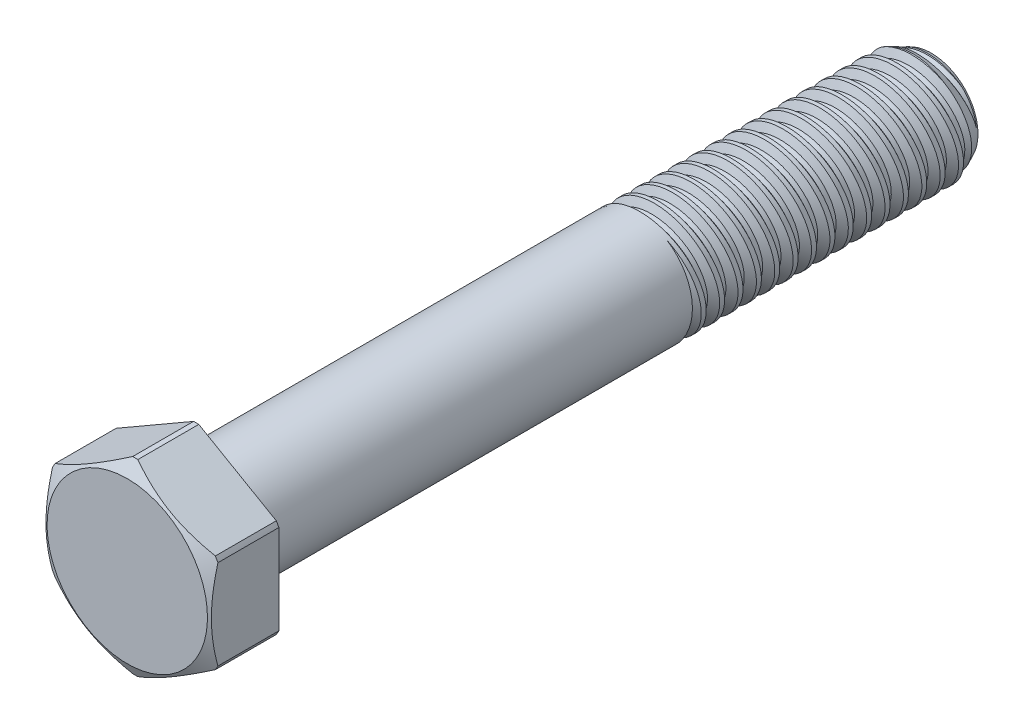
from build123d import *

# Parameters (mm, degrees)
SKETCH1_W            = 25.4
SKETCH1_H            = 4.7625
LPATTERN1_COUNT      = 2
LPATTERN1_PITCH      = 1.5875
LPATTERN1_COUNT_DIR2 = 16
LPATTERN1_PITCH_DIR2 = 1.5875
SKETCH4_W            = 38.1
SKETCH4_H            = 4.7625
EXTRUDE1_DEPTH       = 5.953125
FILLET1_R            = 0.9525


with BuildPart() as part:
    # Sketch1 → Revolve1 (revolve)
    with BuildSketch(Plane(origin=(0, 0, 0), x_dir=(0, 0, -1), z_dir=(1, 0, 0))):
        with Locations((12.7, 2.38125)):
            Rectangle(SKETCH1_W, SKETCH1_H)
    revolve(axis=Axis((0, 0, 0), (0, 0, 1)))

    # Sketch2 → Cut-Revolve1 (revolve, cut)
    with BuildSketch(Plane(origin=(0, 0, 0), x_dir=(0, 0, -1), z_dir=(1, 0, 0))):
        Polygon((1.565900354, 5.023483392), (0.195737544, 4.795122924), (0.82634281, 4.029111805), (1.217817898, 4.094357653), align=None)
    cut_revolve1 = revolve(axis=Axis((0, -0.28317269, 0), (0, 0.164398987, -0.986393924)), mode=Mode.SUBTRACT)

    # Sketch3 → Cut-Revolve2 (revolve, cut)
    with BuildSketch(Plane(origin=(0, 0, 0), x_dir=(0, 0, -1), z_dir=(1, 0, 0))):
        Polygon((23.827243941, 4.7625), (25.4, 4.029111805), (25.4, 4.7625), align=None)
    revolve(axis=Axis((0, 0, 0), (0, 0, -1)), mode=Mode.SUBTRACT)

    # LPattern1: Cut-Revolve1 2 × 16
    with Locations(*[Vector(0, 0, 1) * (i * LPATTERN1_PITCH) + Vector(0, 0, -1) * (j * LPATTERN1_PITCH_DIR2) for i in range(LPATTERN1_COUNT) for j in range(LPATTERN1_COUNT_DIR2) if (i, j) != (0, 0)]):
        add(cut_revolve1, mode=Mode.SUBTRACT)

    # Sketch4 → Revolve2 (revolve)
    with BuildSketch(Plane(origin=(0, 0, 0), x_dir=(0, 0, -1), z_dir=(1, 0, 0))):
        with Locations((-19.05, 2.38125)):
            Rectangle(SKETCH4_W, SKETCH4_H)
    revolve(axis=Axis((0, 0, 38.1), (0, 0, 1)))

    # Sketch5 → Extrude1 (add)
    with BuildSketch(Plane.XY.offset(38.1)):
        Polygon((0, 8.248891971), (-7.14375, 4.124445986), (-7.14375, -4.124445986), (0, -8.248891971), (7.14375, -4.124445986), (7.14375, 4.124445986), align=None)
    extrude(amount=EXTRUDE1_DEPTH)

    # Sketch6 → Cut-Revolve3 (revolve, cut)
    with BuildSketch(Plane(origin=(0, 0, 0), x_dir=(0, 0, -1), z_dir=(1, 0, 0))):
        Polygon((-44.053125, 6.9294375), (-43.36466109, 8.121891971), (-38.1, 8.121891971), (-38.1, 8.629891971), (-44.053125, 8.629891971), align=None)
    revolve(axis=Axis((0, 0, 0), (0, 0, 1)), mode=Mode.SUBTRACT)

    # Fillet1
    fillet1_edges = [part.edges().sort_by_distance(p)[0] for p in [
        (0, -4.7625, 38.1),
    ]]
    fillet(fillet1_edges, radius=FILLET1_R)


solid = part.part
